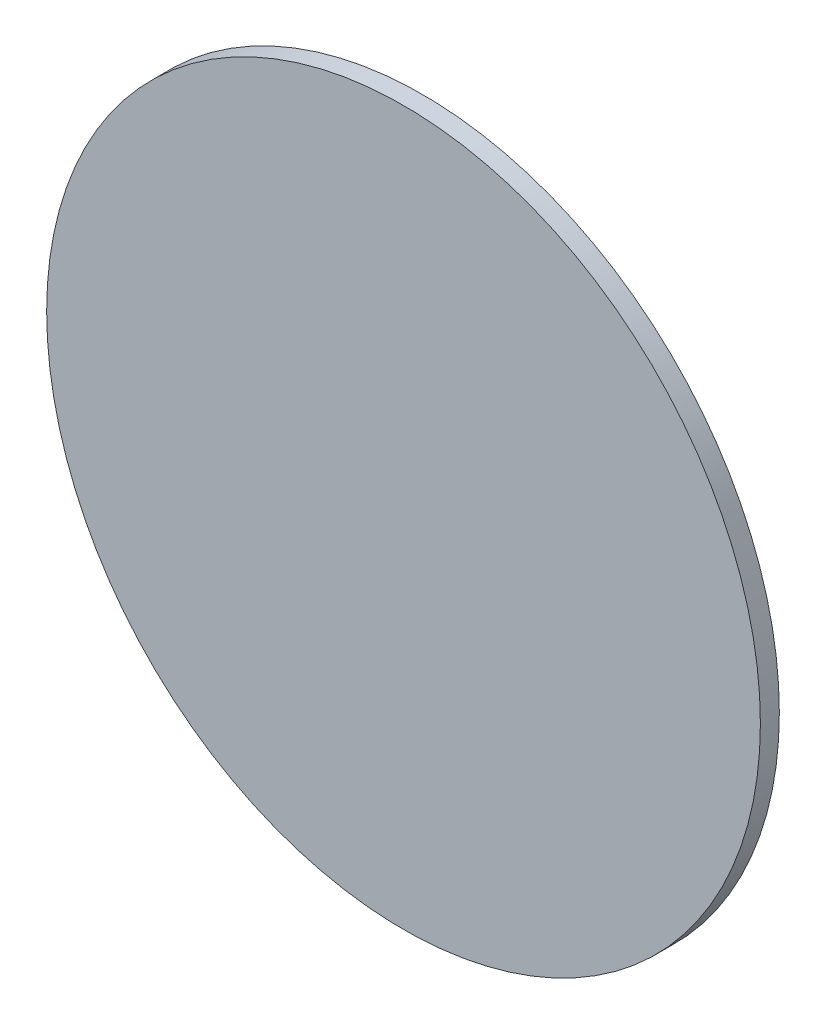
from build123d import *

# Parameters (mm, degrees)
SKETCH1_R           = 128
BOSS_EXTRUDE1_DEPTH = 6.8


with BuildPart() as part:
    # Sketch1 → Boss-Extrude1 (new body)
    with BuildSketch(Plane.XY):
        Circle(SKETCH1_R)
    extrude(amount=BOSS_EXTRUDE1_DEPTH)


solid = part.part
